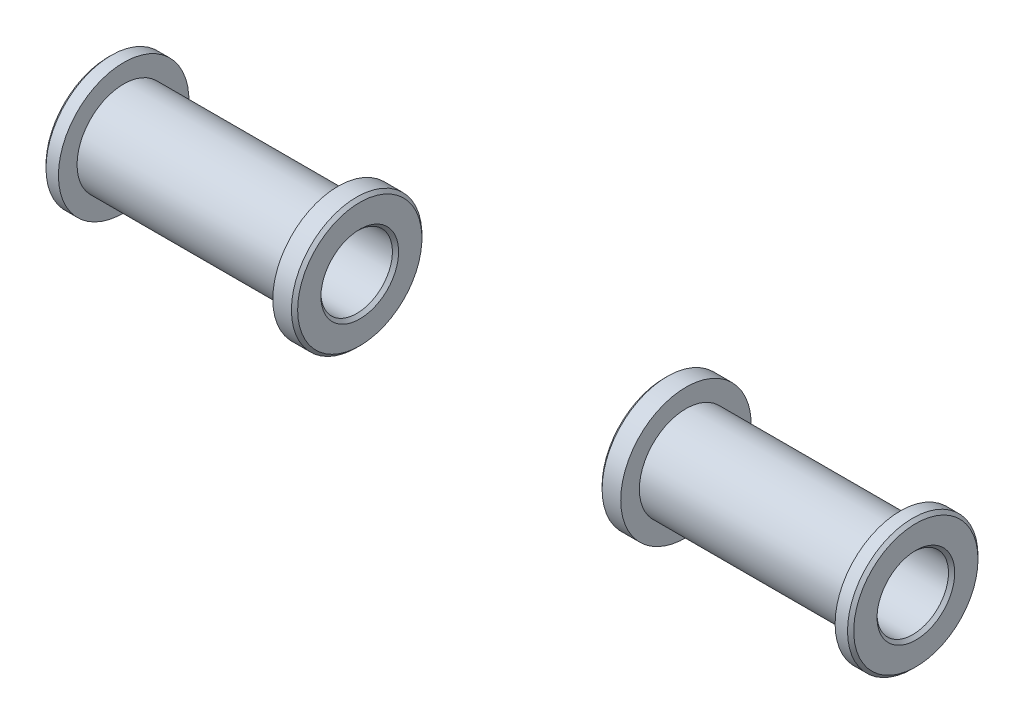
from build123d import *

# Parameters (mm, degrees)
SFAZOWANIE1_SIZE = 1


with BuildPart() as part:
    # Szkic15 → Obrót1 (revolve)
    with BuildSketch(Plane(origin=(0, 0, 0), x_dir=(1, 0, 0), z_dir=(0, 1, 0))):
        Polygon((130, -21), (125, -21), (125, -15), (56, -15), (56, -21), (49, -21), (49, -11.5), (130, -11.5), align=None)
    revolve(axis=Axis((0, 0, 0), (1, 0, 0)))

    # Sfazowanie1
    sfazowanie1_edges = [part.edges().sort_by_distance(p)[0] for p in [
        (49, 0, -11.5),
        (130, 0, -11.5),
        (49, 0, -21),
        (130, 0, -21),
    ]]
    chamfer(sfazowanie1_edges, length=SFAZOWANIE1_SIZE)


with BuildPart() as body_2:
    # Lustro5: mirrored copy
    add(part.part.mirror(Plane(origin=(0, 0, 0), x_dir=(0, 0, 1), z_dir=(1, 0, 0))))


solid = Compound([part.part, body_2.part])
